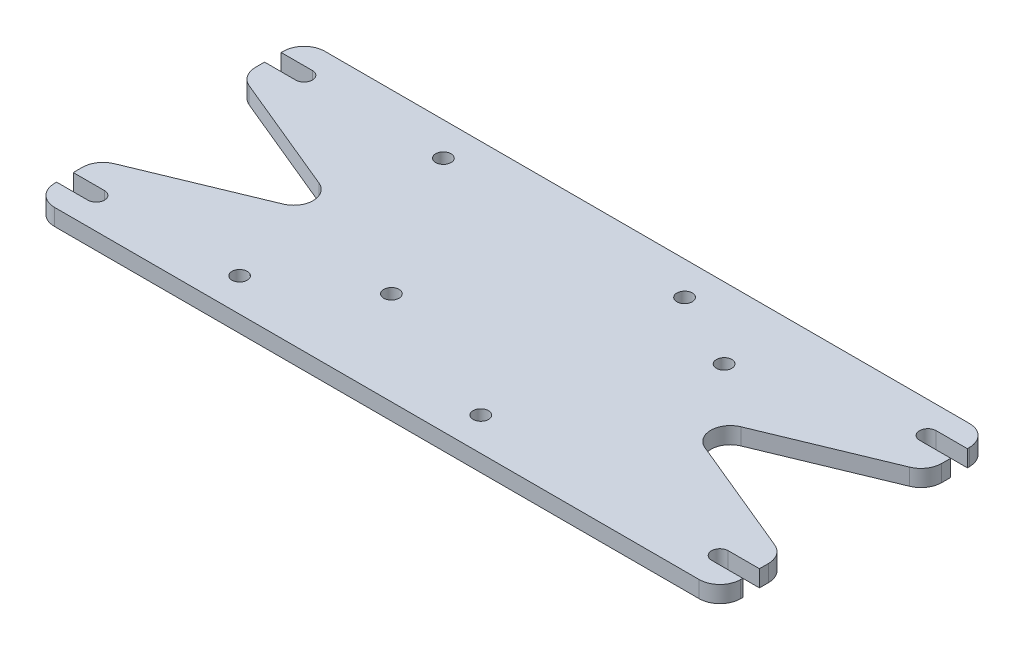
from build123d import *

# Parameters (mm, degrees)
SALIENTE_EXTRUIR1_DEPTH = 4
CROQUIS3_R              = 1.85
CORTAR_EXTRUIR1_DEPTH   = 5
REDONDEO1_R             = 5


with BuildPart() as part:
    # Croquis2 → Saliente-Extruir1 (new body)
    with BuildSketch(Plane(origin=(0, 0, -2.539999962), x_dir=(-1, 0, 0), z_dir=(0, 1, 0))):
        with BuildLine():
            Line((-157.5, 62.039999962), (-165, 62.039999962))
            Line((-165, 62.039999962), (-165, 67.539999962))
            Line((-165, 67.539999962), (0, 67.539999962))
            Line((0, 67.539999962), (0, 62.039999962))
            Line((0, 62.039999962), (-7.5, 62.039999962))
            ThreePointArc((-7.5, 62.039999962), (-9.5, 60.039999962), (-7.5, 58.039999962))
            Line((-7.5, 58.039999962), (0, 58.039999962))
            Line((0, 58.039999962), (0, 52.539999962))
            Line((0, 52.539999962), (-31.793786053, 39.370582579))
            ThreePointArc((-31.793786053, 39.370582579), (-34.687388848, 35.039999962), (-31.793786053, 30.709417344))
            Line((-31.793786053, 30.709417344), (0, 17.539999962))
            Line((0, 17.539999962), (0, 12.039999962))
            Line((0, 12.039999962), (-7.5, 12.039999962))
            ThreePointArc((-7.5, 12.039999962), (-9.5, 10.039999962), (-7.5, 8.039999962))
            Line((-7.5, 8.039999962), (0, 8.039999962))
            Line((0, 8.039999962), (0, 2.539999962))
            Line((0, 2.539999962), (-165, 2.539999962))
            Line((-165, 2.539999962), (-165, 8.039999962))
            Line((-165, 8.039999962), (-157.5, 8.039999962))
            ThreePointArc((-157.5, 8.039999962), (-155.5, 10.039999962), (-157.5, 12.039999962))
            Line((-157.5, 12.039999962), (-165, 12.039999962))
            Line((-165, 12.039999962), (-165, 17.539999962))
            Line((-165, 17.539999962), (-133.206213947, 30.709417344))
            ThreePointArc((-133.206213947, 30.709417344), (-130.312611152, 35.039999962), (-133.206213947, 39.370582579))
            Line((-133.206213947, 39.370582579), (-165, 52.539999962))
            Line((-165, 52.539999962), (-165, 58.039999962))
            Line((-165, 58.039999962), (-157.5, 58.039999962))
            ThreePointArc((-157.5, 58.039999962), (-155.5, 60.039999962), (-157.5, 62.039999962))
        make_face()
    extrude(amount=SALIENTE_EXTRUIR1_DEPTH)

    # Croquis3 → Cortar-Extruir1 (cut, through all)
    with BuildSketch(Plane(origin=(0, 4, 0), x_dir=(-1, 0, 0), z_dir=(0, 1, 0))):
        with Locations((-99.5, 57)):
            Circle(CROQUIS3_R)
        with Locations((-41.5, 57)):
            Circle(CROQUIS3_R)
        with Locations((-41.5, 8)):
            Circle(CROQUIS3_R)
        with Locations((-99.5, 8)):
            Circle(CROQUIS3_R)
        with Locations((-63.5, 42.5)):
            Circle(CROQUIS3_R)
        with Locations((-118.1, 17.1)):
            Circle(CROQUIS3_R)
    extrude(amount=-CORTAR_EXTRUIR1_DEPTH, mode=Mode.SUBTRACT)

    # Redondeo1
    redondeo1_edges = [part.edges().sort_by_distance(p)[0] for p in [
        (165, 2, 65),
        (0, 2, 65),
        (0, 2, 50),
        (0, 2, 15),
        (0, 2, 0),
        (165, 2, 0),
        (165, 2, 15),
        (165, 2, 50),
    ]]
    fillet(redondeo1_edges, radius=REDONDEO1_R)


solid = part.part
